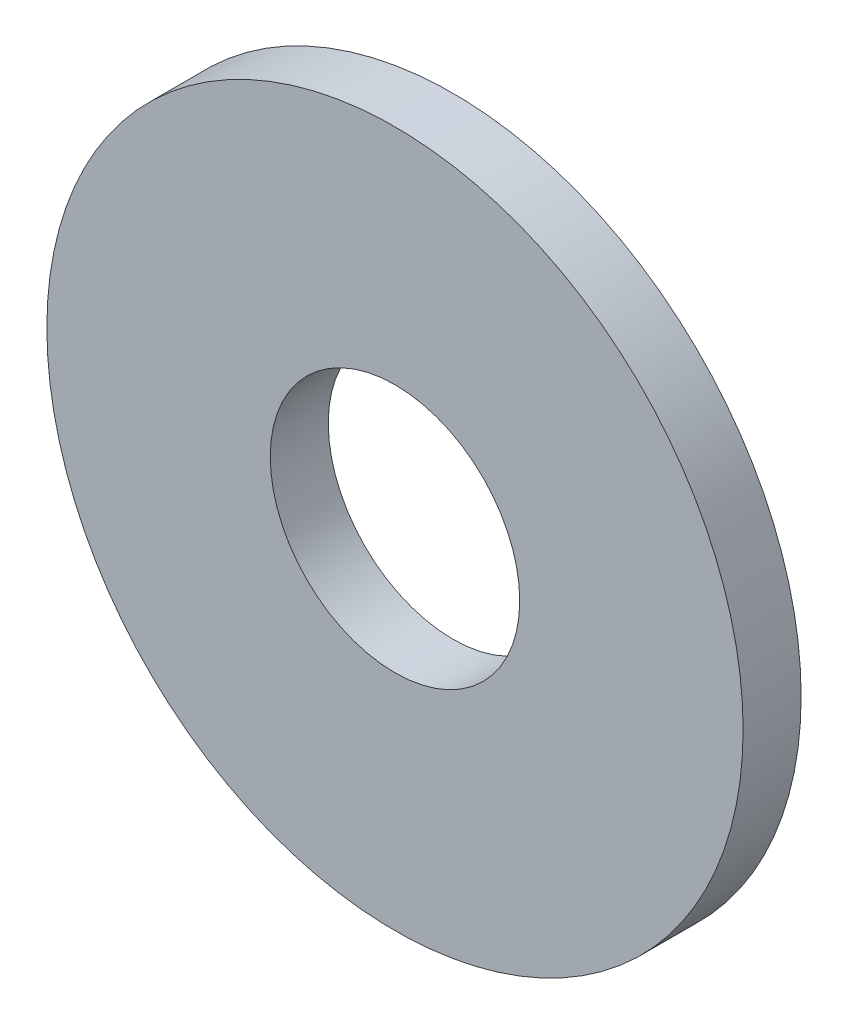
from build123d import *

# Parameters (mm, degrees)
SKETCH1_R          = 6
SKETCH1_R_2        = 2.15
BASE_EXTRUDE_DEPTH = 1


with BuildPart() as part:
    # Sketch1 → Base-Extrude (new body)
    with BuildSketch(Plane.XY):
        Circle(SKETCH1_R)
        Circle(SKETCH1_R_2, mode=Mode.SUBTRACT)
    extrude(amount=-BASE_EXTRUDE_DEPTH)


solid = part.part
